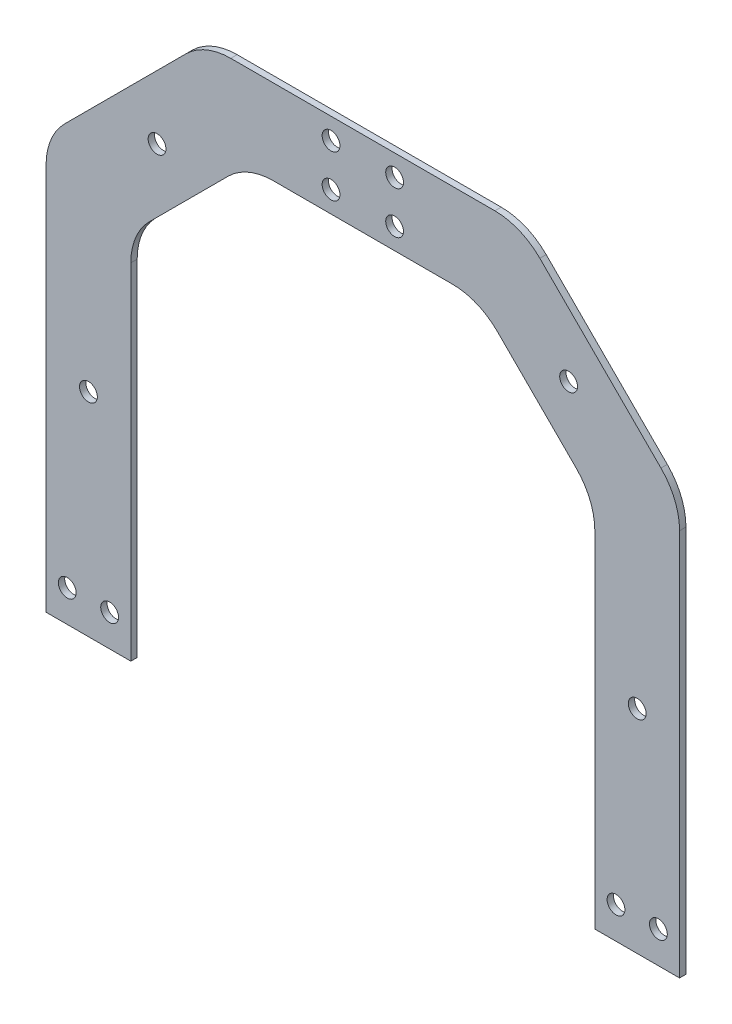
from build123d import *

# Parameters (mm, degrees)
SALIENTE_EXTRUIR1_DEPTH      = 3
TALADRO_DE_MARGEN_PARA_M81_D = 8.4


with BuildPart() as part:
    # Croquis1 → Saliente-Extruir1 (new body)
    with BuildSketch(Plane.XY):
        with BuildLine():
            Line((-63.536796564, 221.213203436), (-100.713203436, 184.036796564))
            ThreePointArc((-100.713203436, 184.036796564), (-107.216385975, 174.3040961), (-109.5, 162.823593129))
            Line((-109.5, 162.823593129), (-109.5, 0))
            Line((-109.5, 0), (-149.5, 0))
            Line((-149.5, 0), (-149.5, 182.823593129))
            ThreePointArc((-149.5, 182.823593129), (-147.216385975, 194.3040961), (-140.713203436, 204.036796564))
            Line((-140.713203436, 204.036796564), (-83.536796564, 261.213203436))
            ThreePointArc((-83.536796564, 261.213203436), (-73.8040961, 267.716385975), (-62.323593129, 270))
            Line((-62.323593129, 270), (62.323593129, 270))
            ThreePointArc((62.323593129, 270), (73.8040961, 267.716385975), (83.536796564, 261.213203436))
            Line((83.536796564, 261.213203436), (140.713203436, 204.036796564))
            ThreePointArc((140.713203436, 204.036796564), (147.216385975, 194.3040961), (149.5, 182.823593129))
            Line((149.5, 182.823593129), (149.5, 0))
            Line((149.5, 0), (109.5, 0))
            Line((109.5, 0), (109.5, 162.823593129))
            ThreePointArc((109.5, 162.823593129), (107.216385975, 174.3040961), (100.713203436, 184.036796564))
            Line((100.713203436, 184.036796564), (63.536796564, 221.213203436))
            ThreePointArc((63.536796564, 221.213203436), (53.8040961, 227.716385975), (42.323593129, 230))
            Line((42.323593129, 230), (-42.323593129, 230))
            ThreePointArc((-42.323593129, 230), (-53.8040961, 227.716385975), (-63.536796564, 221.213203436))
        make_face()
    extrude(amount=SALIENTE_EXTRUIR1_DEPTH)

    # Taladro de margen para M81 (through all)
    with Locations(Plane.XY.offset(3)):
        with Locations((-119.5, 15), (-139.5, 15), (0, 15), (139.5, 15), (-15, 260), (-15, 240), (15, 240), (15, 260), (-129.5, 100.125), (-97.125, 217.625), (129.5, 100.125), (97.125, 217.625), (119.5, 15)):
            Hole(TALADRO_DE_MARGEN_PARA_M81_D / 2)


solid = part.part
